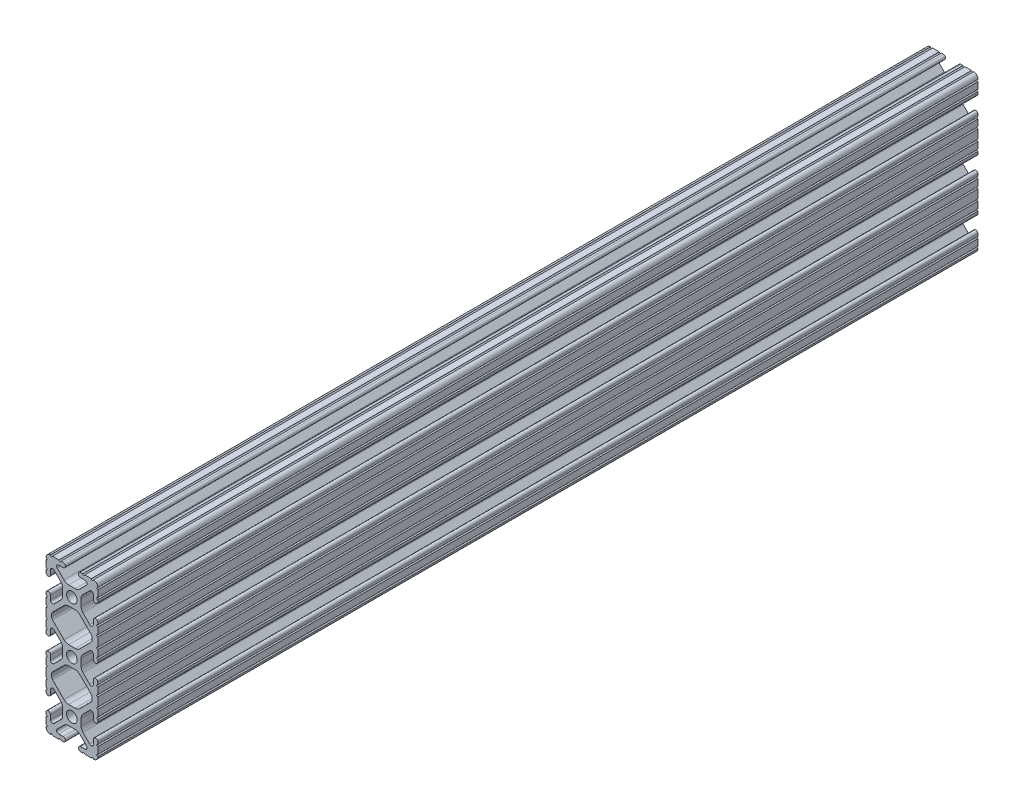
from build123d import *

# Parameters (mm, degrees)
SKETCH1_R           = 2.6035
BOSS_EXTRUDE1_DEPTH = 431.8


with BuildPart() as part:
    # Sketch1 → Boss-Extrude1 (new body)
    with BuildSketch(Plane.XY.offset(431.8)):
        with BuildLine():
            Line((-6.3246, 38.1), (-9.5504, 38.1))
            ThreePointArc((-9.5504, 38.1), (-10.0584, 37.592), (-10.5664, 38.1))
            ThreePointArc((-10.5664, 38.1), (-12.082677406, 37.482677406), (-12.7, 35.9664))
            ThreePointArc((-12.7, 35.9664), (-12.192, 35.4584), (-12.7, 34.9504))
            Line((-12.7, 34.9504), (-12.7, 31.7246))
            ThreePointArc((-12.7, 31.7246), (-12.192, 31.2166), (-12.7, 30.7086))
            Line((-12.7, 30.7086), (-12.7, 29.702307889))
            ThreePointArc((-12.7, 29.702307889), (-11.5951, 28.597407889), (-10.4902, 29.702307889))
            Line((-10.4902, 29.702307889), (-10.4902, 31.874794456))
            ThreePointArc((-10.4902, 31.874794456), (-9.863006367, 32.813456061), (-8.75577951, 32.593214945))
            Line((-8.75577951, 32.593214945), (-5.43843597, 29.275871405))
            ThreePointArc((-5.43843597, 29.275871405), (-4.750182484, 28.245827272), (-4.5085, 27.030807374))
            Line((-4.5085, 27.030807374), (-4.5085, 23.769192626))
            ThreePointArc((-4.5085, 23.769192626), (-4.750182484, 22.554172728), (-5.43843597, 21.524128595))
            Line((-5.43843597, 21.524128595), (-8.75577951, 18.206785055))
            ThreePointArc((-8.75577951, 18.206785055), (-9.863006367, 17.986543939), (-10.4902, 18.925205544))
            Line((-10.4902, 18.925205544), (-10.4902, 21.097692111))
            ThreePointArc((-10.4902, 21.097692111), (-11.5951, 22.202592111), (-12.7, 21.097692111))
            Line((-12.7, 21.097692111), (-12.7, 20.0914))
            ThreePointArc((-12.7, 20.0914), (-12.192, 19.5834), (-12.7, 19.0754))
            Line((-12.7, 19.0754), (-12.7, 15.8496))
            ThreePointArc((-12.7, 15.8496), (-12.192, 15.3416), (-12.7, 14.8336))
            Line((-12.7, 14.8336), (-12.7, 10.5664))
            ThreePointArc((-12.7, 10.5664), (-12.192, 10.0584), (-12.7, 9.5504))
            Line((-12.7, 9.5504), (-12.7, 6.3246))
            ThreePointArc((-12.7, 6.3246), (-12.192, 5.8166), (-12.7, 5.3086))
            Line((-12.7, 5.3086), (-12.7, 4.302307889))
            ThreePointArc((-12.7, 4.302307889), (-11.5951, 3.197407889), (-10.4902, 4.302307889))
            Line((-10.4902, 4.302307889), (-10.4902, 6.474794456))
            ThreePointArc((-10.4902, 6.474794456), (-9.863006367, 7.413456061), (-8.75577951, 7.193214945))
            Line((-8.75577951, 7.193214945), (-5.43843597, 3.875871405))
            ThreePointArc((-5.43843597, 3.875871405), (-4.750182484, 2.845827272), (-4.5085, 1.630807374))
            Line((-4.5085, 1.630807374), (-4.5085, -1.630807374))
            ThreePointArc((-4.5085, -1.630807374), (-4.750182484, -2.845827272), (-5.43843597, -3.875871405))
            Line((-5.43843597, -3.875871405), (-8.75577951, -7.193214945))
            ThreePointArc((-8.75577951, -7.193214945), (-9.863006367, -7.413456061), (-10.4902, -6.474794456))
            Line((-10.4902, -6.474794456), (-10.4902, -4.302307889))
            ThreePointArc((-10.4902, -4.302307889), (-11.5951, -3.197407889), (-12.7, -4.302307889))
            Line((-12.7, -4.302307889), (-12.7, -5.3086))
            ThreePointArc((-12.7, -5.3086), (-12.192, -5.8166), (-12.7, -6.3246))
            Line((-12.7, -6.3246), (-12.7, -9.5504))
            ThreePointArc((-12.7, -9.5504), (-12.192, -10.0584), (-12.7, -10.5664))
            Line((-12.7, -10.5664), (-12.7, -14.8336))
            ThreePointArc((-12.7, -14.8336), (-12.192, -15.3416), (-12.7, -15.8496))
            Line((-12.7, -15.8496), (-12.7, -19.0754))
            ThreePointArc((-12.7, -19.0754), (-12.192, -19.5834), (-12.7, -20.0914))
            Line((-12.7, -20.0914), (-12.7, -21.097692111))
            ThreePointArc((-12.7, -21.097692111), (-11.5951, -22.202592111), (-10.4902, -21.097692111))
            Line((-10.4902, -21.097692111), (-10.4902, -18.925205544))
            ThreePointArc((-10.4902, -18.925205544), (-9.863006367, -17.986543939), (-8.75577951, -18.206785055))
            Line((-8.75577951, -18.206785055), (-5.43843597, -21.524128595))
            ThreePointArc((-5.43843597, -21.524128595), (-4.750182484, -22.554172728), (-4.5085, -23.769192626))
            Line((-4.5085, -23.769192626), (-4.5085, -27.030807374))
            ThreePointArc((-4.5085, -27.030807374), (-4.750182484, -28.245827272), (-5.43843597, -29.275871405))
            Line((-5.43843597, -29.275871405), (-8.75577951, -32.593214945))
            ThreePointArc((-8.75577951, -32.593214945), (-9.863006367, -32.813456061), (-10.4902, -31.874794456))
            Line((-10.4902, -31.874794456), (-10.4902, -29.702307889))
            ThreePointArc((-10.4902, -29.702307889), (-11.5951, -28.597407889), (-12.7, -29.702307889))
            Line((-12.7, -29.702307889), (-12.7, -30.7086))
            ThreePointArc((-12.7, -30.7086), (-12.192, -31.2166), (-12.7, -31.7246))
            Line((-12.7, -31.7246), (-12.7, -34.9504))
            ThreePointArc((-12.7, -34.9504), (-12.192, -35.4584), (-12.7, -35.9664))
            ThreePointArc((-12.7, -35.9664), (-12.082677406, -37.482677406), (-10.5664, -38.1))
            ThreePointArc((-10.5664, -38.1), (-10.0584, -37.592), (-9.5504, -38.1))
            Line((-9.5504, -38.1), (-6.3246, -38.1))
            ThreePointArc((-6.3246, -38.1), (-5.8166, -37.592), (-5.3086, -38.1))
            Line((-5.3086, -38.1), (-4.302307889, -38.1))
            ThreePointArc((-4.302307889, -38.1), (-3.197407889, -36.9951), (-4.302307889, -35.8902))
            Line((-4.302307889, -35.8902), (-6.474794456, -35.8902))
            ThreePointArc((-6.474794456, -35.8902), (-7.413456061, -35.263006367), (-7.193214945, -34.15577951))
            Line((-7.193214945, -34.15577951), (-3.875871405, -30.838435969))
            ThreePointArc((-3.875871405, -30.838435969), (-2.845827272, -30.150182484), (-1.630807374, -29.9085))
            Line((-1.630807374, -29.9085), (1.630807374, -29.9085))
            ThreePointArc((1.630807374, -29.9085), (2.845827272, -30.150182484), (3.875871404, -30.838435969))
            Line((3.875871404, -30.838435969), (7.193214945, -34.15577951))
            ThreePointArc((7.193214945, -34.15577951), (7.41345606, -35.263006367), (6.474794455, -35.8902))
            Line((6.474794455, -35.8902), (4.302307889, -35.8902))
            ThreePointArc((4.302307889, -35.8902), (3.197407889, -36.9951), (4.302307889, -38.1))
            Line((4.302307889, -38.1), (5.3086, -38.1))
            ThreePointArc((5.3086, -38.1), (5.8166, -37.592), (6.3246, -38.1))
            Line((6.3246, -38.1), (9.5504, -38.1))
            ThreePointArc((9.5504, -38.1), (10.0584, -37.592), (10.5664, -38.1))
            ThreePointArc((10.5664, -38.1), (12.082677406, -37.482677406), (12.7, -35.9664))
            ThreePointArc((12.7, -35.9664), (12.192, -35.4584), (12.7, -34.9504))
            Line((12.7, -34.9504), (12.7, -31.7246))
            ThreePointArc((12.7, -31.7246), (12.192, -31.2166), (12.7, -30.7086))
            Line((12.7, -30.7086), (12.7, -29.702307918))
            ThreePointArc((12.7, -29.702307918), (11.5951, -28.597407918), (10.4902, -29.702307918))
            Line((10.4902, -29.702307918), (10.4902, -31.874794456))
            ThreePointArc((10.4902, -31.874794456), (9.863006367, -32.813456061), (8.75577951, -32.593214945))
            Line((8.75577951, -32.593214945), (5.43843597, -29.275871405))
            ThreePointArc((5.43843597, -29.275871405), (4.750182484, -28.245827272), (4.5085, -27.030807374))
            Line((4.5085, -27.030807374), (4.5085, -23.769192625))
            ThreePointArc((4.5085, -23.769192625), (4.750182484, -22.554172727), (5.43843597, -21.524128595))
            Line((5.43843597, -21.524128595), (8.75577951, -18.206785054))
            ThreePointArc((8.75577951, -18.206785054), (9.863006367, -17.986543939), (10.4902, -18.925205544))
            Line((10.4902, -18.925205544), (10.4902, -21.097692058))
            ThreePointArc((10.4902, -21.097692058), (11.5951, -22.202592058), (12.7, -21.097692058))
            Line((12.7, -21.097692058), (12.7, -20.0914))
            ThreePointArc((12.7, -20.0914), (12.192, -19.5834), (12.7, -19.0754))
            Line((12.7, -19.0754), (12.7, -15.8496))
            ThreePointArc((12.7, -15.8496), (12.192, -15.3416), (12.7, -14.8336))
            Line((12.7, -14.8336), (12.7, -10.5664))
            ThreePointArc((12.7, -10.5664), (12.192, -10.0584), (12.7, -9.5504))
            Line((12.7, -9.5504), (12.7, -6.3246))
            ThreePointArc((12.7, -6.3246), (12.192, -5.8166), (12.7, -5.3086))
            Line((12.7, -5.3086), (12.7, -4.302307889))
            ThreePointArc((12.7, -4.302307889), (11.5951, -3.197407889), (10.4902, -4.302307889))
            Line((10.4902, -4.302307889), (10.4902, -6.474794456))
            ThreePointArc((10.4902, -6.474794456), (9.863006367, -7.413456061), (8.75577951, -7.193214945))
            Line((8.75577951, -7.193214945), (5.43843597, -3.875871405))
            ThreePointArc((5.43843597, -3.875871405), (4.750182484, -2.845827272), (4.5085, -1.630807374))
            Line((4.5085, -1.630807374), (4.5085, 1.630807374))
            ThreePointArc((4.5085, 1.630807374), (4.750182484, 2.845827272), (5.43843597, 3.875871405))
            Line((5.43843597, 3.875871405), (8.75577951, 7.193214945))
            ThreePointArc((8.75577951, 7.193214945), (9.863006367, 7.413456061), (10.4902, 6.474794456))
            Line((10.4902, 6.474794456), (10.4902, 4.302307889))
            ThreePointArc((10.4902, 4.302307889), (11.5951, 3.197407889), (12.7, 4.302307889))
            Line((12.7, 4.302307889), (12.7, 5.3086))
            ThreePointArc((12.7, 5.3086), (12.192, 5.8166), (12.7, 6.3246))
            Line((12.7, 6.3246), (12.7, 9.5504))
            ThreePointArc((12.7, 9.5504), (12.192, 10.0584), (12.7, 10.5664))
            Line((12.7, 10.5664), (12.7, 14.8336))
            ThreePointArc((12.7, 14.8336), (12.192, 15.3416), (12.7, 15.8496))
            Line((12.7, 15.8496), (12.7, 19.0754))
            ThreePointArc((12.7, 19.0754), (12.192, 19.5834), (12.7, 20.0914))
            Line((12.7, 20.0914), (12.7, 21.097692082))
            ThreePointArc((12.7, 21.097692082), (11.5951, 22.202592082), (10.4902, 21.097692082))
            Line((10.4902, 21.097692082), (10.4902, 18.925205544))
            ThreePointArc((10.4902, 18.925205544), (9.863006367, 17.986543939), (8.75577951, 18.206785055))
            Line((8.75577951, 18.206785055), (5.43843597, 21.524128595))
            ThreePointArc((5.43843597, 21.524128595), (4.750182484, 22.554172728), (4.5085, 23.769192626))
            Line((4.5085, 23.769192626), (4.5085, 27.030807374))
            ThreePointArc((4.5085, 27.030807374), (4.750182484, 28.245827272), (5.43843597, 29.275871405))
            Line((5.43843597, 29.275871405), (8.75577951, 32.593214945))
            ThreePointArc((8.75577951, 32.593214945), (9.863006367, 32.813456061), (10.4902, 31.874794456))
            Line((10.4902, 31.874794456), (10.4902, 29.702307889))
            ThreePointArc((10.4902, 29.702307889), (11.5951, 28.597407889), (12.7, 29.702307889))
            Line((12.7, 29.702307889), (12.7, 30.7086))
            ThreePointArc((12.7, 30.7086), (12.192, 31.2166), (12.7, 31.7246))
            Line((12.7, 31.7246), (12.7, 34.9504))
            ThreePointArc((12.7, 34.9504), (12.192, 35.4584), (12.7, 35.9664))
            ThreePointArc((12.7, 35.9664), (12.082677406, 37.482677406), (10.5664, 38.1))
            ThreePointArc((10.5664, 38.1), (10.0584, 37.592), (9.5504, 38.1))
            Line((9.5504, 38.1), (6.3246, 38.1))
            ThreePointArc((6.3246, 38.1), (5.8166, 37.592), (5.3086, 38.1))
            Line((5.3086, 38.1), (4.302307889, 38.1))
            ThreePointArc((4.302307889, 38.1), (3.197407889, 36.9951), (4.302307889, 35.8902))
            Line((4.302307889, 35.8902), (6.474794456, 35.8902))
            ThreePointArc((6.474794456, 35.8902), (7.413456061, 35.263006367), (7.193214945, 34.15577951))
            Line((7.193214945, 34.15577951), (3.875871405, 30.83843597))
            ThreePointArc((3.875871405, 30.83843597), (2.845827272, 30.150182484), (1.630807374, 29.9085))
            Line((1.630807374, 29.9085), (-1.630807374, 29.9085))
            ThreePointArc((-1.630807374, 29.9085), (-2.845827272, 30.150182484), (-3.875871405, 30.83843597))
            Line((-3.875871405, 30.83843597), (-7.193214945, 34.15577951))
            ThreePointArc((-7.193214945, 34.15577951), (-7.413456061, 35.263006367), (-6.474794456, 35.8902))
            Line((-6.474794456, 35.8902), (-4.302307889, 35.8902))
            ThreePointArc((-4.302307889, 35.8902), (-3.197407889, 36.9951), (-4.302307889, 38.1))
            Line((-4.302307889, 38.1), (-5.3086, 38.1))
            ThreePointArc((-5.3086, 38.1), (-5.8166, 37.592), (-6.3246, 38.1))
        make_face()
        with Locations((0, 25.4)):
            Circle(SKETCH1_R, mode=Mode.SUBTRACT)
        with Locations((0, -25.4)):
            Circle(SKETCH1_R, mode=Mode.SUBTRACT)
        Circle(SKETCH1_R, mode=Mode.SUBTRACT)
        with BuildLine():
            Line((-9.9314, 12.146268083), (-9.9314, 13.253731917))
            ThreePointArc((-9.9314, 13.253731917), (-9.811525488, 13.856381786), (-9.470151759, 14.367283676))
            Line((-9.470151759, 14.367283676), (-3.875871405, 19.96156403))
            ThreePointArc((-3.875871405, 19.96156403), (-2.845827272, 20.649817516), (-1.630807374, 20.8915))
            Line((-1.630807374, 20.8915), (1.630807374, 20.8915))
            ThreePointArc((1.630807374, 20.8915), (2.845827272, 20.649817516), (3.875871405, 19.96156403))
            Line((3.875871405, 19.96156403), (9.470151759, 14.367283676))
            ThreePointArc((9.470151759, 14.367283676), (9.811525488, 13.856381786), (9.9314, 13.253731917))
            Line((9.9314, 13.253731917), (9.9314, 12.146268083))
            ThreePointArc((9.9314, 12.146268083), (9.811525488, 11.543618214), (9.470151759, 11.032716324))
            Line((9.470151759, 11.032716324), (3.875871405, 5.43843597))
            ThreePointArc((3.875871405, 5.43843597), (2.845827272, 4.750182484), (1.630807374, 4.5085))
            Line((1.630807374, 4.5085), (-1.630807374, 4.5085))
            ThreePointArc((-1.630807374, 4.5085), (-2.845827272, 4.750182484), (-3.875871405, 5.43843597))
            Line((-3.875871405, 5.43843597), (-9.470151759, 11.032716324))
            ThreePointArc((-9.470151759, 11.032716324), (-9.811525488, 11.543618214), (-9.9314, 12.146268083))
        make_face(mode=Mode.SUBTRACT)
        with BuildLine():
            Line((-9.9314, -13.253731917), (-9.9314, -12.146268083))
            ThreePointArc((-9.9314, -12.146268083), (-9.811525488, -11.543618214), (-9.470151759, -11.032716324))
            Line((-9.470151759, -11.032716324), (-3.875871405, -5.43843597))
            ThreePointArc((-3.875871405, -5.43843597), (-2.845827272, -4.750182484), (-1.630807374, -4.5085))
            Line((-1.630807374, -4.5085), (1.630807374, -4.5085))
            ThreePointArc((1.630807374, -4.5085), (2.845827272, -4.750182484), (3.875871405, -5.43843597))
            Line((3.875871405, -5.43843597), (9.470151759, -11.032716324))
            ThreePointArc((9.470151759, -11.032716324), (9.811525488, -11.543618214), (9.9314, -12.146268083))
            Line((9.9314, -12.146268083), (9.9314, -13.253731917))
            ThreePointArc((9.9314, -13.253731917), (9.811525488, -13.856381786), (9.470151759, -14.367283676))
            Line((9.470151759, -14.367283676), (3.875871405, -19.96156403))
            ThreePointArc((3.875871405, -19.96156403), (2.845827272, -20.649817516), (1.630807374, -20.8915))
            Line((1.630807374, -20.8915), (-1.630807374, -20.8915))
            ThreePointArc((-1.630807374, -20.8915), (-2.845827272, -20.649817516), (-3.875871405, -19.96156403))
            Line((-3.875871405, -19.96156403), (-9.470151759, -14.367283676))
            ThreePointArc((-9.470151759, -14.367283676), (-9.811525488, -13.856381786), (-9.9314, -13.253731917))
        make_face(mode=Mode.SUBTRACT)
    extrude(amount=-BOSS_EXTRUDE1_DEPTH)


solid = part.part
